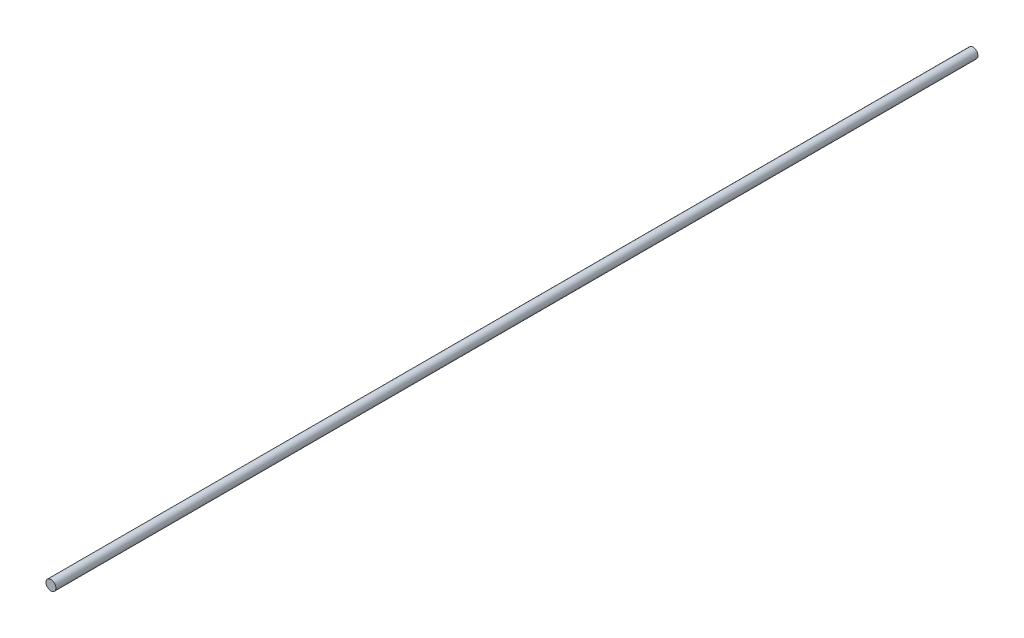
from build123d import *

# Parameters (mm, degrees)
SKETCH1_R           = 1.5
BOSS_EXTRUDE1_DEPTH = 279


with BuildPart() as part:
    # Sketch1 → Boss-Extrude1 (new body)
    with BuildSketch(Plane.XY):
        Circle(SKETCH1_R)
    extrude(amount=BOSS_EXTRUDE1_DEPTH)


solid = part.part
